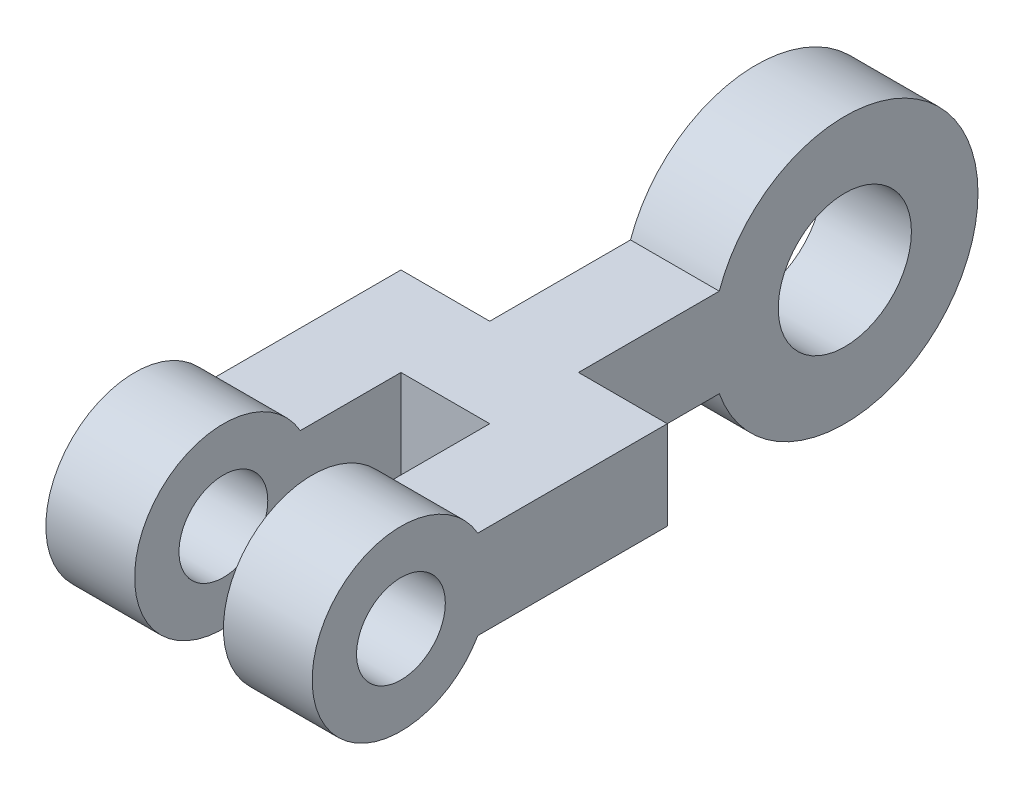
from build123d import *

# Parameters (mm, degrees)
SKETCH1_R           = 9.525
BOSS_EXTRUDE1_DEPTH = 6.35
SKETCH1_3_W         = 12.7
SKETCH1_3_H         = 12.7
BOSS_EXTRUDE2_DEPTH = 19.05
BOSS_EXTRUDE3_START = 6.35
SKETCH1_4_R         = 6.35
BOSS_EXTRUDE3_DEPTH = 12.7


with BuildPart() as part:
    # Sketch1 → Boss-Extrude1 (new, symmetric)
    with BuildSketch(Plane(origin=(0, 0, 0), x_dir=(0, 0, -1), z_dir=(1, 0, 0))):
        with BuildLine():
            Line((38.1, 6.35), (38.1, -6.35))
            Line((38.1, -6.35), (58.239487758, -6.35))
            ThreePointArc((58.239487758, -6.35), (95.25, 0), (58.239487758, 6.35))
            Line((58.239487758, 6.35), (38.1, 6.35))
        make_face()
        with Locations((76.2, 0)):
            Circle(SKETCH1_R, mode=Mode.SUBTRACT)
    extrude(amount=BOSS_EXTRUDE1_DEPTH, both=True)

    # Sketch1_3 → Boss-Extrude2 (add, symmetric)
    with BuildSketch(Plane(origin=(0, 0, 0), x_dir=(0, 0, -1), z_dir=(1, 0, 0))):
        with Locations((31.75, 0)):
            Rectangle(SKETCH1_3_W, SKETCH1_3_H)
    extrude(amount=BOSS_EXTRUDE2_DEPTH, both=True)


with BuildPart() as body_2:
    # Sketch1_4 → Boss-Extrude3 (new body)
    with BuildSketch(Plane(origin=(0, 0, 0), x_dir=(0, 0, -1), z_dir=(1, 0, 0)).offset(BOSS_EXTRUDE3_START)):
        with BuildLine():
            Line((25.4, 6.35), (10.998522628, 6.35))
            ThreePointArc((10.998522628, 6.35), (-12.7, 0), (10.998522628, -6.35))
            Line((10.998522628, -6.35), (25.4, -6.35))
            Line((25.4, -6.35), (25.4, 6.35))
        make_face()
        Circle(SKETCH1_4_R, mode=Mode.SUBTRACT)
    boss_extrude3 = extrude(amount=BOSS_EXTRUDE3_DEPTH)


with BuildPart() as part_1:
    add(part.part)

    # Mirror2: Boss-Extrude3 across plane
    add(boss_extrude3.mirror(Plane(origin=(0, 0, 0), x_dir=(0, 0, 1), z_dir=(1, 0, 0))))


with BuildPart() as body_2_1:
    add(body_2.part)

    # Combine1: union part
    add(part_1.part)


solid = body_2_1.part
